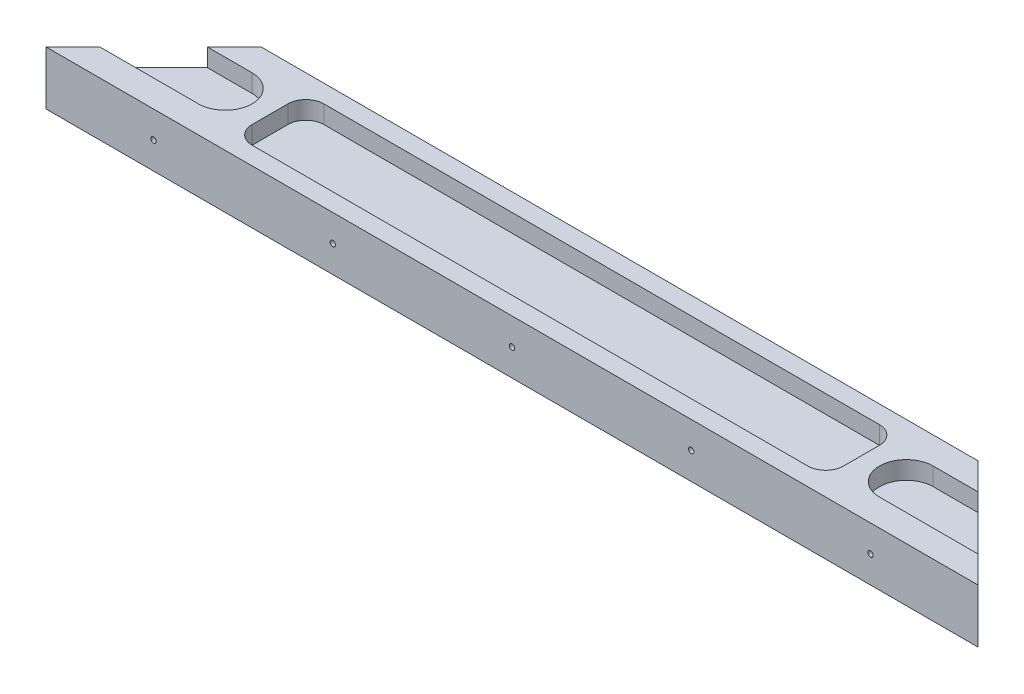
from build123d import *

# Parameters (mm, degrees)
BOSS_EXTRUDE1_DEPTH = 15
CUT_EXTRUDE1_DEPTH  = 5
SKETCH3_R           = 0.75
CUT_EXTRUDE2_DEPTH  = 30
CUT_EXTRUDE3_DEPTH  = 5


with BuildPart() as part:
    # Sketch1 → Boss-Extrude1 (new body)
    with BuildSketch(Plane(origin=(0, 0, 0), x_dir=(1, 0, 0), z_dir=(0, 1, 0))):
        Polygon((0, 0), (260, 0), (230, 30), (30, 30), align=None)
    extrude(amount=BOSS_EXTRUDE1_DEPTH)

    # Sketch2 → Cut-Extrude1 (cut)
    with BuildSketch(Plane(origin=(0, 15, 0), x_dir=(1, 0, 0), z_dir=(0, 1, 0))):
        with BuildLine():
            Line((-5, 22.5), (35, 22.5))
            ThreePointArc((35, 22.5), (42.5, 15), (35, 7.5))
            Line((35, 7.5), (-5, 7.5))
            ThreePointArc((-5, 7.5), (-12.5, 15), (-5, 22.5))
        make_face()
        with BuildLine():
            Line((265, 22.5), (225, 22.5))
            ThreePointArc((225, 22.5), (217.5, 15), (225, 7.5))
            Line((225, 7.5), (265, 7.5))
            ThreePointArc((265, 7.5), (272.5, 15), (265, 22.5))
        make_face()
    extrude(amount=-CUT_EXTRUDE1_DEPTH, mode=Mode.SUBTRACT)

    # Sketch3 → Cut-Extrude2 (cut)
    with BuildSketch(Plane.XY):
        with Locations((130, 7.5)):
            Circle(SKETCH3_R)
        with Locations((180, 7.5)):
            Circle(SKETCH3_R)
        with Locations((230, 7.5)):
            Circle(SKETCH3_R)
        with Locations((80, 7.5)):
            Circle(SKETCH3_R)
        with Locations((30, 7.5)):
            Circle(SKETCH3_R)
    extrude(amount=-CUT_EXTRUDE2_DEPTH, mode=Mode.SUBTRACT)

    # Sketch4 → Cut-Extrude3 (cut)
    with BuildSketch(Plane(origin=(0, 15, 0), x_dir=(1, 0, 0), z_dir=(0, 1, 0))):
        with BuildLine():
            Line((52.5, 25), (207.5, 25))
            ThreePointArc((207.5, 25), (211.035533906, 23.535533906), (212.5, 20))
            Line((212.5, 20), (212.5, 10))
            ThreePointArc((212.5, 10), (211.035533906, 6.464466094), (207.5, 5))
            Line((207.5, 5), (52.5, 5))
            ThreePointArc((52.5, 5), (48.964466094, 6.464466094), (47.5, 10))
            Line((47.5, 10), (47.5, 20))
            ThreePointArc((47.5, 20), (48.964466094, 23.535533906), (52.5, 25))
        make_face()
    extrude(amount=-CUT_EXTRUDE3_DEPTH, mode=Mode.SUBTRACT)


solid = part.part
